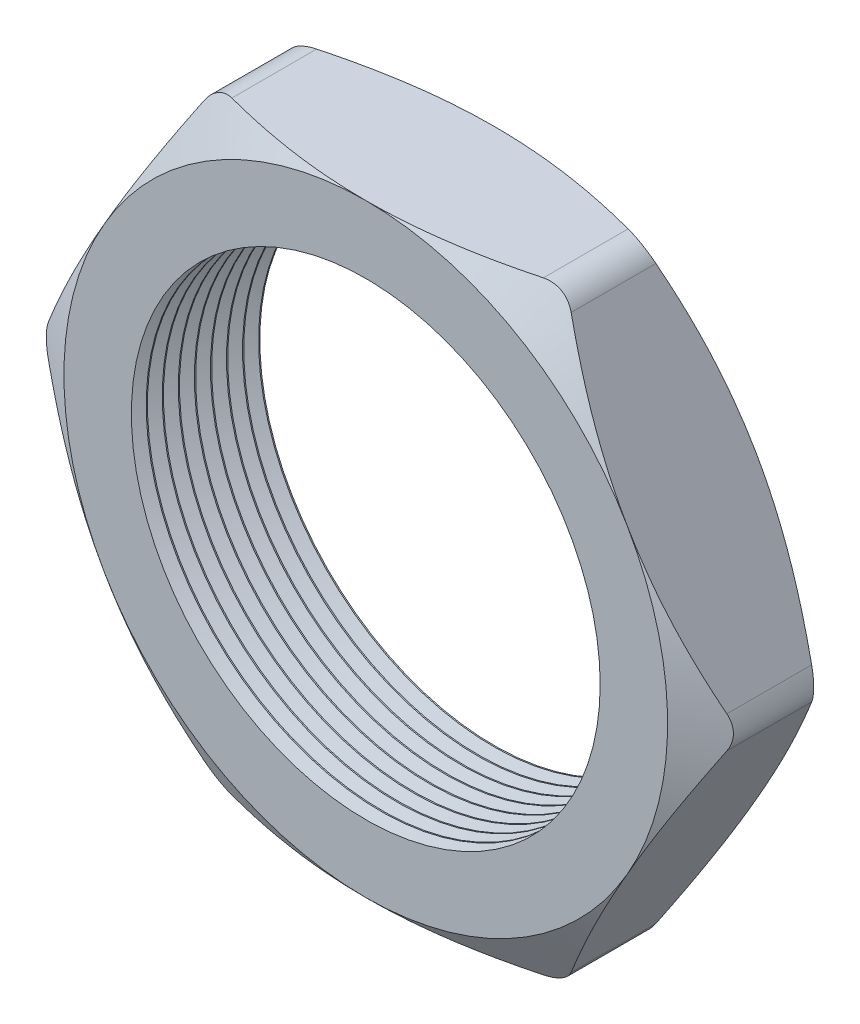
from build123d import *

# Parameters (mm, degrees)
SKETCH1_R          = 9.271
EXTRUDE1_DEPTH     = 5.08
SKETCH2_OUTSIDE_W  = 57.996
SKETCH2_OUTSIDE_H  = 54.302
SKETCH2_OUTSIDE_R  = 11.938
CUT_EXTRUDE1_DEPTH = 6.08
CUT_EXTRUDE1_DRAFT = -60
SKETCH3_OUTSIDE_W  = 57.996
SKETCH3_OUTSIDE_H  = 54.302
SKETCH3_OUTSIDE_R  = 11.938
CUT_EXTRUDE2_DEPTH = 6.08
CUT_EXTRUDE2_DRAFT = -60
FILLET1_R          = 1.27
LPATTERN1_COUNT    = 8
LPATTERN1_PITCH    = 0.635


with BuildPart() as part:
    # Sketch1 → Extrude1 (new body)
    with BuildSketch(Plane.XY):
        Polygon((-13.784815027, 0), (-6.892407514, -11.938), (6.892407514, -11.938), (13.784815027, 0), (6.892407514, 11.938), (-6.892407514, 11.938), align=None)
        Circle(SKETCH1_R, mode=Mode.SUBTRACT)
    extrude(amount=EXTRUDE1_DEPTH)


with BuildPart() as cut_extrude1_tool:
    # Sketch2 outside → Cut-Extrude1 (with draft: the straight prism first)
    with BuildSketch(Plane.XY.offset(5.08)):
        Rectangle(SKETCH2_OUTSIDE_W, SKETCH2_OUTSIDE_H)
        Circle(SKETCH2_OUTSIDE_R, mode=Mode.SUBTRACT)
    extrude(amount=-CUT_EXTRUDE1_DEPTH)
    # Cut-Extrude1: the draft: its side faces are tilted about the plane it starts from
    cut_extrude1_sides = [cut_extrude1_tool.faces().sort_by_distance(p)[0] for p in [
        (0, -27.151, 2.04),
        (28.998, 0, 2.04),
        (0, 27.151, 2.04),
        (-28.998, 0, 2.04),
        (-11.938, 0, 2.04),
    ]]
    draft(cut_extrude1_sides, Plane.XY.offset(5.08), CUT_EXTRUDE1_DRAFT)


with BuildPart() as part_1:
    add(part.part)

    # Cut-Extrude1: cut by cut_extrude1_tool
    add(cut_extrude1_tool.part, mode=Mode.SUBTRACT)


with BuildPart() as cut_extrude2_tool:
    # Sketch3 outside → Cut-Extrude2 (with draft: the straight prism first)
    with BuildSketch(Plane(origin=(0, 0, 0), x_dir=(-1, 0, 0), z_dir=(0, 0, -1))):
        Rectangle(SKETCH3_OUTSIDE_W, SKETCH3_OUTSIDE_H)
        Circle(SKETCH3_OUTSIDE_R, mode=Mode.SUBTRACT)
    extrude(amount=-CUT_EXTRUDE2_DEPTH)
    # Cut-Extrude2: the draft: its side faces are tilted about the plane it starts from
    cut_extrude2_sides = [cut_extrude2_tool.faces().sort_by_distance(p)[0] for p in [
        (0, -27.151, 3.04),
        (-28.998, 0, 3.04),
        (0, 27.151, 3.04),
        (28.998, 0, 3.04),
        (11.938, 0, 3.04),
    ]]
    draft(cut_extrude2_sides, Plane(origin=(0, 0, 0), x_dir=(-1, 0, 0), z_dir=(0, 0, -1)), CUT_EXTRUDE2_DRAFT)


with BuildPart() as part_2:
    add(part_1.part)

    # Cut-Extrude2: cut by cut_extrude2_tool
    add(cut_extrude2_tool.part, mode=Mode.SUBTRACT)

    # Fillet1
    fillet1_edges = [part_2.edges().sort_by_distance(p)[0] for p in [
        (13.784815027, 0, 2.54),
        (6.892407514, -11.938, 2.54),
        (-6.892407514, -11.938, 2.54),
        (-13.784815027, 0, 2.54),
        (-6.892407514, 11.938, 2.54),
        (6.892407514, 11.938, 2.54),
    ]]
    fillet(fillet1_edges, radius=FILLET1_R)

    # Sketch4 → Cut-Revolve1 (revolve, cut)
    with BuildSketch(Plane(origin=(0, 0, 0), x_dir=(1, 0, 0), z_dir=(0, 1, 0)), mode=Mode.PRIVATE) as cut_revolve1_sk:
        Polygon((-9.271, -5.08), (-9.271, -4.493412127), (-9.779, -4.786706063), align=None)
    cut_revolve1 = revolve(cut_revolve1_sk.sketch.rotate(Axis((0, 0, 0), (0, 0, 1)), 180), axis=Axis((0, 0, 0), (0, 0, 1)), mode=Mode.SUBTRACT)  # turned: the seam where the file's is

    # LPattern1: Cut-Revolve1 ×8
    with Locations(*[(0, 0, -i * LPATTERN1_PITCH) for i in range(1, LPATTERN1_COUNT)]):
        add(cut_revolve1, mode=Mode.SUBTRACT)


solid = part_2.part
